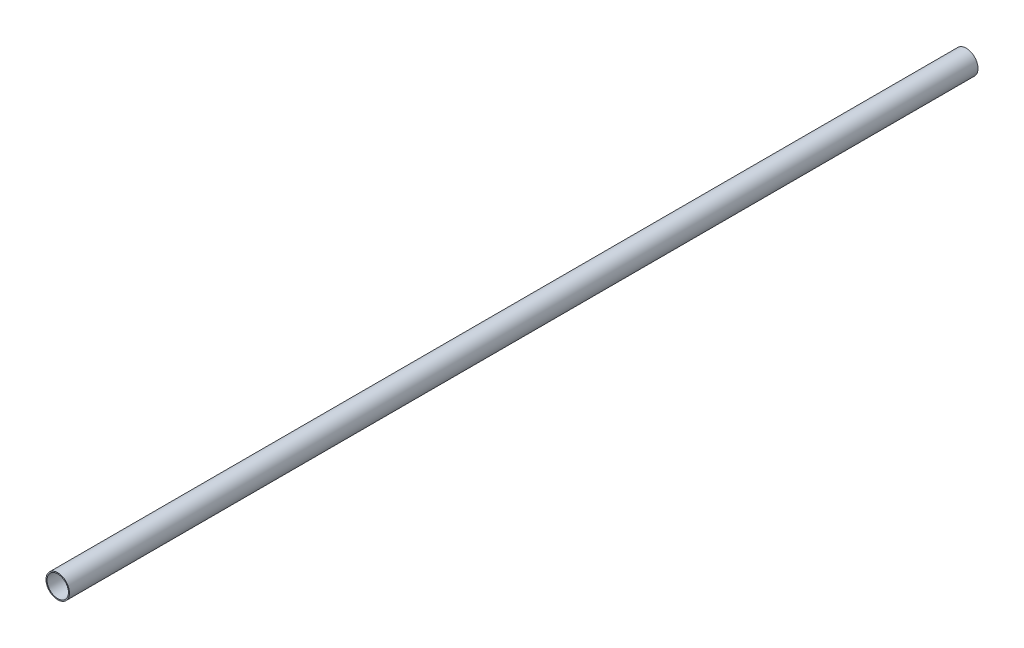
from build123d import *

# Parameters (mm, degrees)
SKETCH1_R           = 11
SKETCH1_R_2         = 10
BOSS_EXTRUDE1_DEPTH = 850


with BuildPart() as part:
    # Sketch1 → Boss-Extrude1 (new body)
    with BuildSketch(Plane.XY):
        Circle(SKETCH1_R)
        Circle(SKETCH1_R_2, mode=Mode.SUBTRACT)
    extrude(amount=BOSS_EXTRUDE1_DEPTH)


solid = part.part
